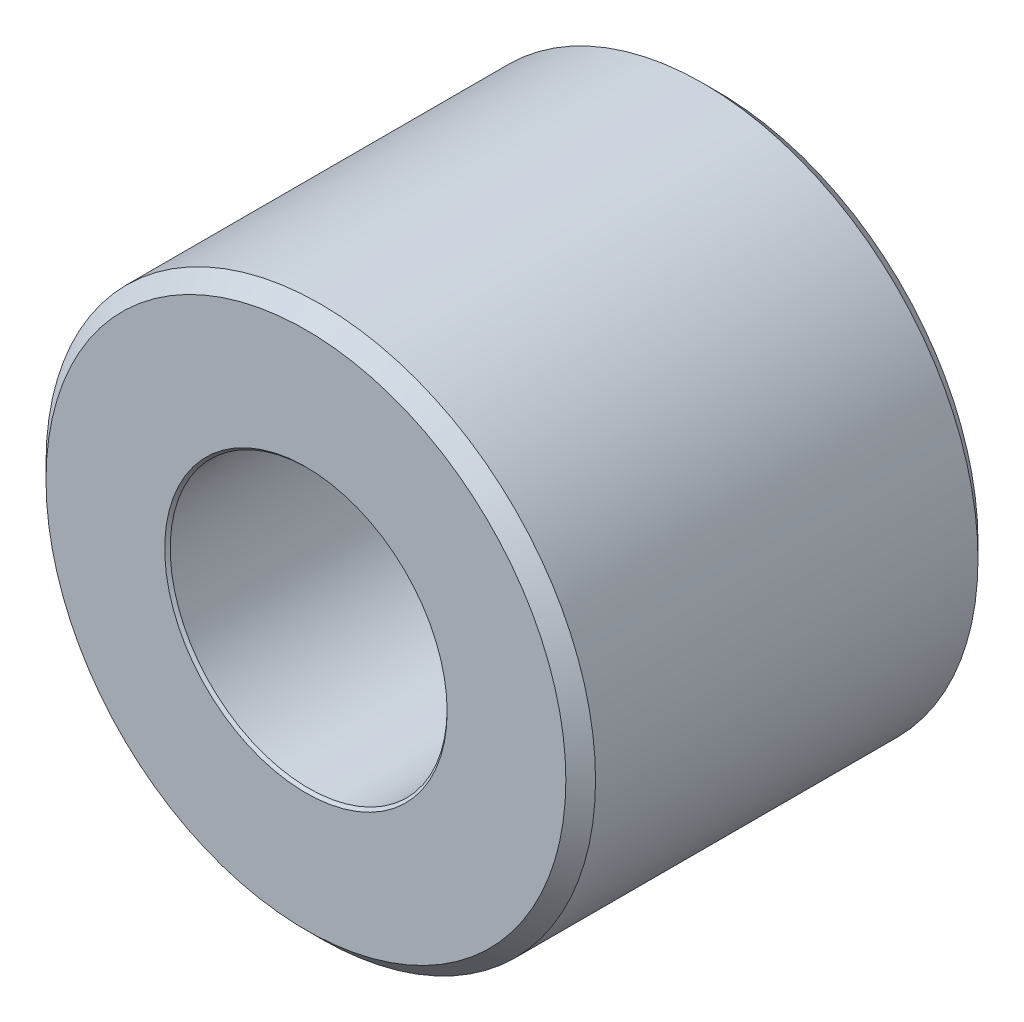
from build123d import *

# Parameters (mm, degrees)
BOSS_EXTRUDE1_DEPTH      = 2.38125
BOSS_EXTRUDE1_DEPTH_BACK = 2.38125
SKETCH3_R                = 3.175
SKETCH3_R_2              = 1.4605
CHAMFER1_SIZE            = 0.17145
CUT_EXTRUDE1_DEPTH       = 6.082479863
CUT_EXTRUDE1_DEPTH_BACK  = 6.082479863
SKETCH4_R                = 1.6002


with BuildPart() as part:
    # Sketch3 → Boss-Extrude1 (new, two sides: drawn at the far end of the back side and taken through both)
    with BuildSketch(Plane.XY.offset(-BOSS_EXTRUDE1_DEPTH_BACK)):
        Circle(SKETCH3_R)
        Circle(SKETCH3_R_2, mode=Mode.SUBTRACT)
    extrude(amount=BOSS_EXTRUDE1_DEPTH + BOSS_EXTRUDE1_DEPTH_BACK)

    # Chamfer1
    chamfer1_edges = [part.edges().sort_by_distance(p)[0] for p in [
        (-3.175, 0, -2.38125),
        (-1.4605, 0, -2.38125),
        (-3.175, 0, 2.38125),
        (-1.4605, 0, 2.38125),
    ]]
    chamfer(chamfer1_edges, length=CHAMFER1_SIZE)

    # Sketch4 → Cut-Extrude1 (cut, two sides: drawn at the far end of the back side and taken through both)
    with BuildSketch(Plane.XY.offset(-CUT_EXTRUDE1_DEPTH_BACK)):
        Circle(SKETCH4_R)
    extrude(amount=CUT_EXTRUDE1_DEPTH + CUT_EXTRUDE1_DEPTH_BACK, mode=Mode.SUBTRACT)


solid = part.part
